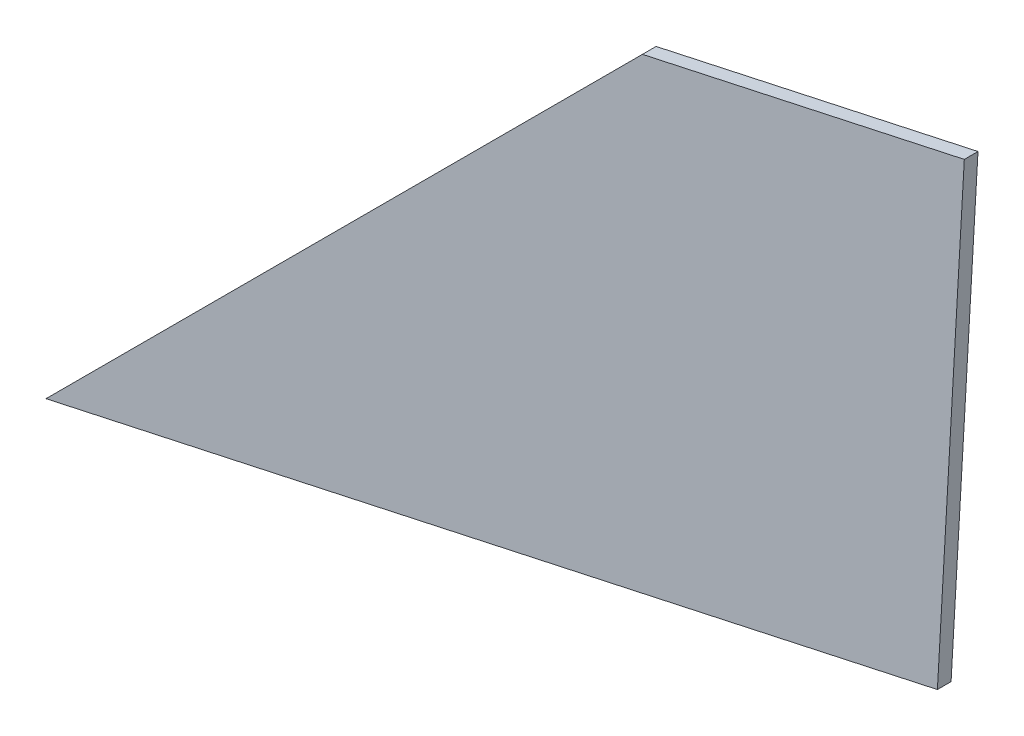
from build123d import *

# Parameters (mm, degrees)
BOSS_EXTRUDE1_DEPTH = 2.7


with BuildPart() as part:
    # Sketch1 → Boss-Extrude1 (new body)
    with BuildSketch(Plane.XY):
        Polygon((0, 0), (175.891745506, 38.23733598), (181.202486614, 131.493949841), (117.686022959, 117.686022959), align=None)
    extrude(amount=BOSS_EXTRUDE1_DEPTH)


solid = part.part
